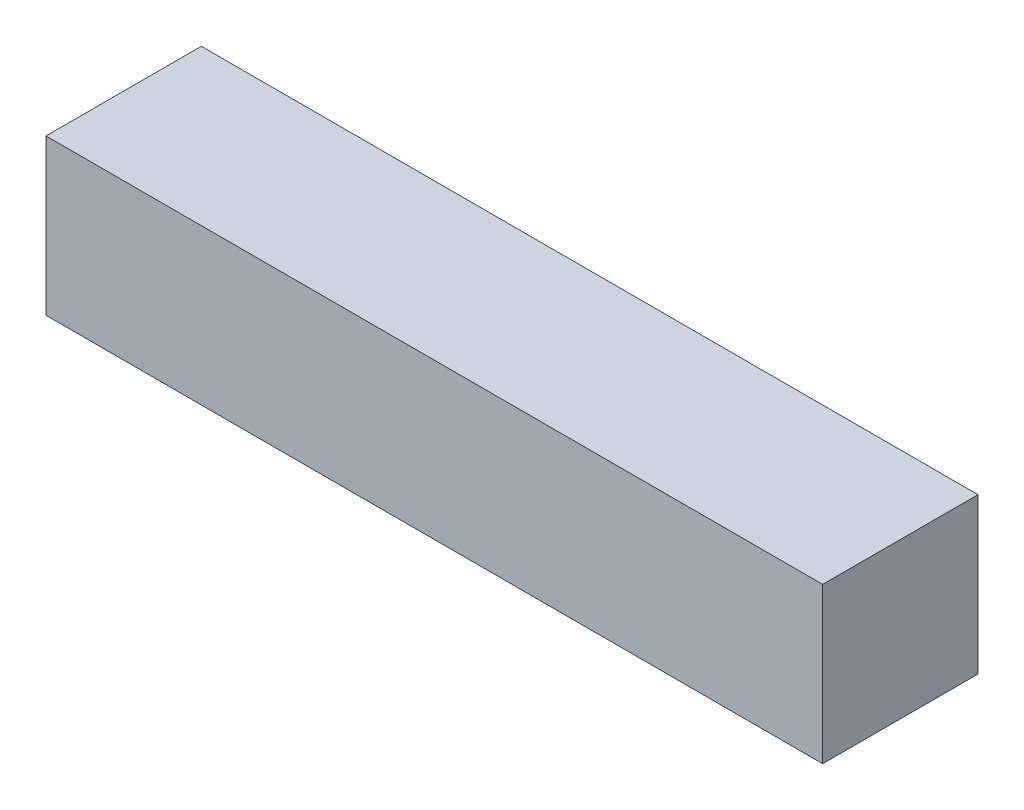
from build123d import *

# Parameters (mm, degrees)
SKETCH1_W           = 127
SKETCH1_H           = 25.4
BOSS_EXTRUDE1_DEPTH = 25.4


with BuildPart() as part:
    # Sketch1 → Boss-Extrude1 (new body)
    with BuildSketch(Plane.XY):
        with Locations((63.5, 12.7)):
            Rectangle(SKETCH1_W, SKETCH1_H)
    extrude(amount=BOSS_EXTRUDE1_DEPTH)


solid = part.part
